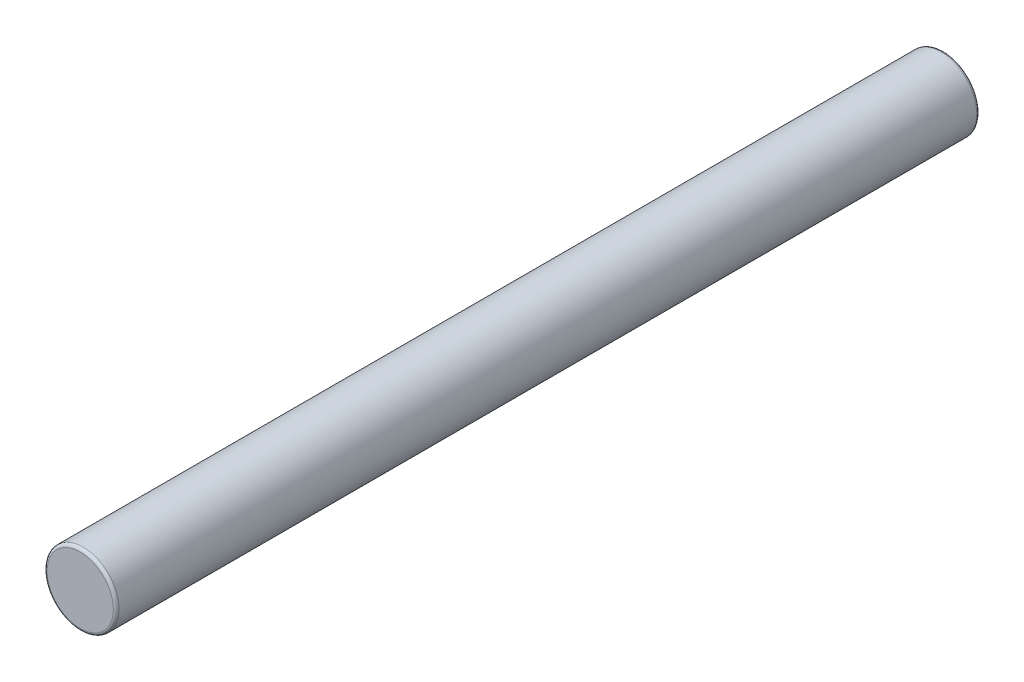
from build123d import *

# Parameters (mm, degrees)
SKETCH1_R           = 2.5
BOSS_EXTRUDE1_DEPTH = 60
FILLET1_R           = 0.2


with BuildPart() as part:
    # Sketch1 → Boss-Extrude1 (new body)
    with BuildSketch(Plane.XY):
        Circle(SKETCH1_R)
    extrude(amount=BOSS_EXTRUDE1_DEPTH)

    # Fillet1
    fillet1_edges = [part.edges().sort_by_distance(p)[0] for p in [
        (-2.5, 0, 0),
        (-2.5, 0, 60),
    ]]
    fillet(fillet1_edges, radius=FILLET1_R)


solid = part.part
